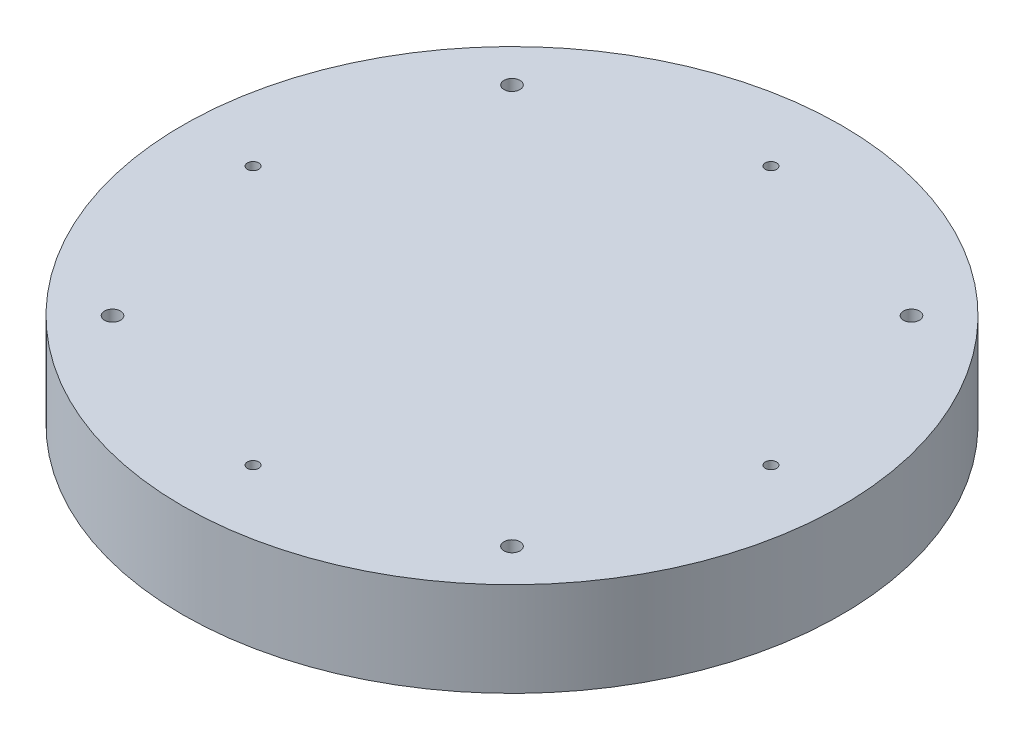
from build123d import *

# Parameters (mm, degrees)
SKETCH1_R                        = 175
BOSS_EXTRUDE1_DEPTH              = 30
TAP_DRILL_FOR_M10X1_5_TAP1_D     = 8.5
TAP_DRILL_FOR_M10X1_5_TAP1_DEPTH = 20
TAP_DRILL_FOR_M10X1_5_TAP1_TIP   = 2.553657631
BOSS_EXTRUDE2_START              = 20
SKETCH7_R                        = 175
BOSS_EXTRUDE2_DEPTH              = 20
F_6_0_6_DIAMETER_HOLE1_D         = 6
TAP_DRILL_FOR_M7X1_0_TAP2_D      = 6
TAP_DRILL_FOR_M7X1_0_TAP2_DEPTH  = 20
TAP_DRILL_FOR_M7X1_0_TAP2_TIP    = 1.802581857


with BuildPart() as part:
    # Sketch1 → Boss-Extrude1 (new body)
    with BuildSketch(Plane(origin=(0, 0, 0), x_dir=(1, 0, 0), z_dir=(0, 1, 0))):
        Circle(SKETCH1_R)
    extrude(amount=BOSS_EXTRUDE1_DEPTH)

    # Tap Drill for M10x1.5 Tap1
    with Locations(Plane(origin=(0, 30, 0), x_dir=(1, 0, 0), z_dir=(0, 1, 0))):
        with Locations((-106.066017178, -106.066017178), (106.066017178, -106.066017178), (106.066017178, 106.066017178), (-106.066017178, 106.066017178)):
            Hole(TAP_DRILL_FOR_M10X1_5_TAP1_D / 2, depth=TAP_DRILL_FOR_M10X1_5_TAP1_DEPTH)
            with Locations((0, 0, -(TAP_DRILL_FOR_M10X1_5_TAP1_DEPTH + TAP_DRILL_FOR_M10X1_5_TAP1_TIP / 2))):  # 118° drill point
                Cone(0, TAP_DRILL_FOR_M10X1_5_TAP1_D / 2, TAP_DRILL_FOR_M10X1_5_TAP1_TIP, mode=Mode.SUBTRACT)

    # Sketch7 → Boss-Extrude2 (add)
    with BuildSketch(Plane.XZ.offset(BOSS_EXTRUDE2_START)):
        Circle(SKETCH7_R)
    extrude(amount=-BOSS_EXTRUDE2_DEPTH)

    # Ø6.0 (6) Diameter Hole1 (through all)
    with Locations(Plane(origin=(0, 30, 0), x_dir=(1, 0, 0), z_dir=(0, 1, 0))):
        with Locations((-137.5, 0), (0, -137.5), (137.5, 0), (0, 137.5)):
            Hole(F_6_0_6_DIAMETER_HOLE1_D / 2)

    # Tap Drill for M7x1.0 Tap2
    with Locations(Plane(origin=(0, -20, 0), x_dir=(-1, 0, 0), z_dir=(0, -1, 0))):
        with Locations((78.367338092, 0.001727747), (-0.067861908, -78.484272253), (-78.503061908, 0.001727747), (-0.067861908, 78.487727747)):
            Hole(TAP_DRILL_FOR_M7X1_0_TAP2_D / 2, depth=TAP_DRILL_FOR_M7X1_0_TAP2_DEPTH)
            with Locations((0, 0, -(TAP_DRILL_FOR_M7X1_0_TAP2_DEPTH + TAP_DRILL_FOR_M7X1_0_TAP2_TIP / 2))):  # 118° drill point
                Cone(0, TAP_DRILL_FOR_M7X1_0_TAP2_D / 2, TAP_DRILL_FOR_M7X1_0_TAP2_TIP, mode=Mode.SUBTRACT)


solid = part.part
